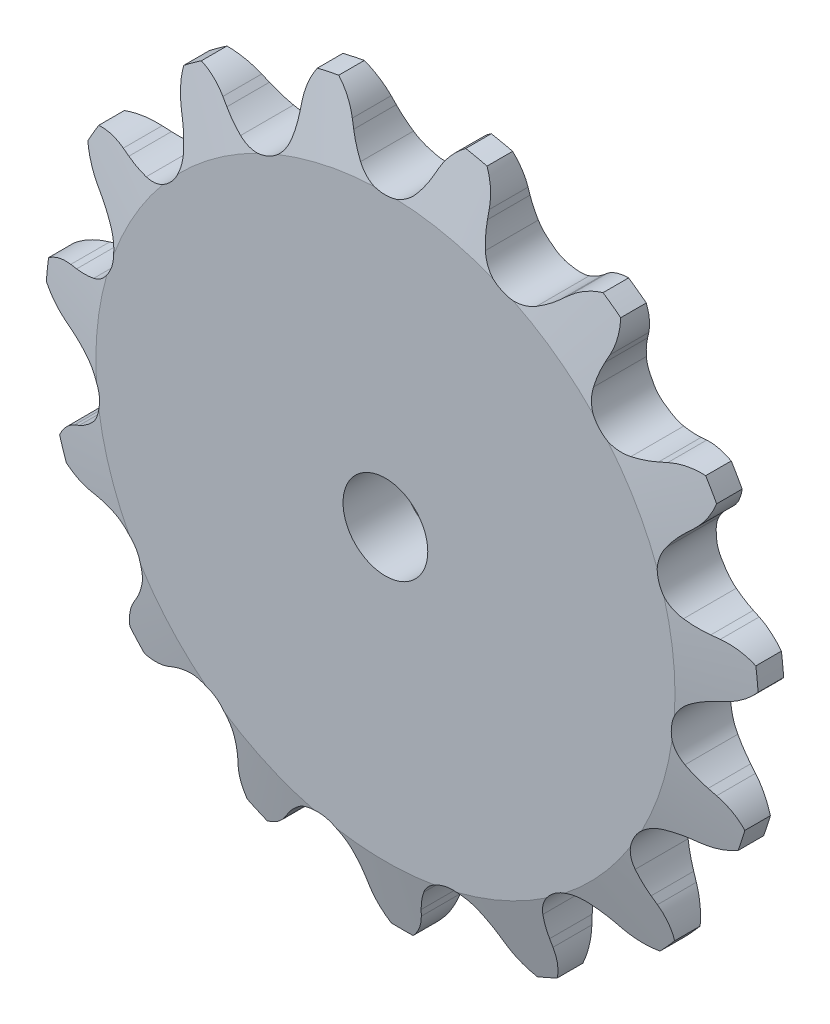
from build123d import *

# Parameters (mm, degrees)
TOOTH_CUT_NUMBER_OF_TEETH_15_DEPTH = 24.859401731
TOOTH_PATTERN_15_15_COUNT          = 15
CUT_EXTRUDE1_DEPTH                 = 24.826805435
CUT_EXTRUDE1_DEPTH_BACK            = 24.826805435
SKETCH4_R                          = 2


with BuildPart() as part:
    # Sprocket-BaseSketch → 25 _04C_ ANSI _ISO_ Chain Number_ 1.202i (revolve)
    with BuildSketch(Plane(origin=(0, 0, 0), x_dir=(0, 0, -1), z_dir=(1, 0, 0))):
        Polygon((1.397, 0), (1.397, 13.667200598), (0.60325, 16.842200598), (-0.60325, 16.842200598), (-1.397, 13.667200598), (-1.397, 0), align=None)
    revolve(axis=Axis((0, 0, -5.588), (0, 0, 1)))

    # Tooth-Sketch → Tooth-Cut_ Number of teeth_ 15 (cut, symmetric)
    with BuildSketch(Plane.XY):
        with BuildLine():
            Line((1.888011838, 15.117919819), (2.041958482, 15.452111555))
            ThreePointArc((2.041958482, 15.452111555), (3.049444923, 16.609051494), (4.521780729, 17.040057561))
            ThreePointArc((4.521780729, 17.040057561), (0, 17.629806086), (-4.521780729, 17.040057561))
            ThreePointArc((-4.521780729, 17.040057561), (-3.049444923, 16.609051494), (-2.041958482, 15.452111555))
            Line((-2.041958482, 15.452111555), (-1.888011838, 15.117919819))
            ThreePointArc((-1.888011838, 15.117919819), (-1.632074491, 14.642592583), (-1.319092583, 14.202726432))
            ThreePointArc((-1.319092583, 14.202726432), (0, 13.573551545), (1.319092583, 14.202726432))
            ThreePointArc((1.319092583, 14.202726432), (1.632074491, 14.642592583), (1.888011838, 15.117919819))
        make_face()
    tooth_cut_number_of_teeth_15 = extrude(amount=TOOTH_CUT_NUMBER_OF_TEETH_15_DEPTH, both=True, mode=Mode.SUBTRACT)

    # Tooth Pattern_ 15 _ 15: Tooth-Cut_ Number of teeth_ 15 ×15 about axis
    tooth_pattern_15_15_axis = Axis((0, 0, -88.99), (0, 0, 1))
    for i in range(1, TOOTH_PATTERN_15_15_COUNT):
        add(tooth_cut_number_of_teeth_15.rotate(tooth_pattern_15_15_axis, i * 360 / TOOTH_PATTERN_15_15_COUNT), mode=Mode.SUBTRACT)

    # Sketch4 → Cut-Extrude1 (cut, two sides: drawn at the far end of the back side and taken through both)
    with BuildSketch(Plane.XY.offset(-CUT_EXTRUDE1_DEPTH_BACK)):
        Circle(SKETCH4_R)
    extrude(amount=CUT_EXTRUDE1_DEPTH + CUT_EXTRUDE1_DEPTH_BACK, mode=Mode.SUBTRACT)


solid = part.part
